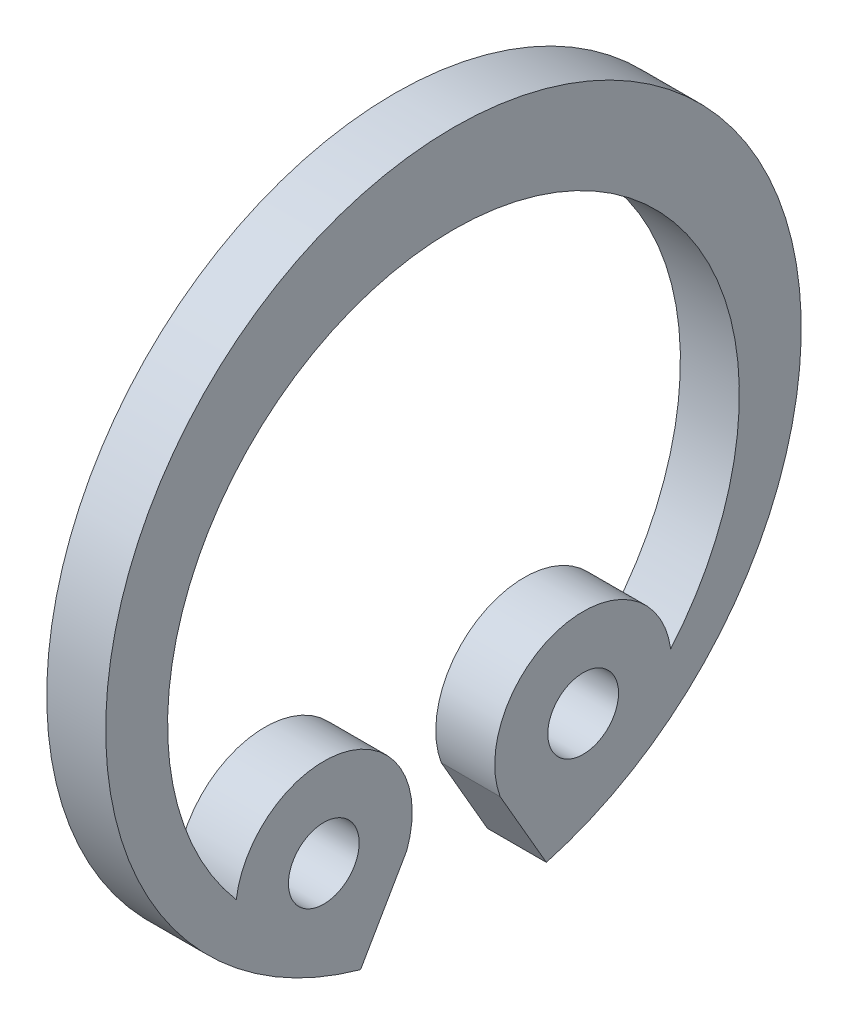
from build123d import *

# Parameters (mm, degrees)
BOSS_EXTRUDE1_DEPTH      = 0.5
BOSS_EXTRUDE1_DEPTH_BACK = 0.5
SKETCH1_R                = 0.6


with BuildPart() as part:
    # Sketch1 → Boss-Extrude1 (new, two sides: drawn at the far end of the back side and taken through both)
    with BuildSketch(Plane(origin=(0, 0, 0), x_dir=(0, 0, -1), z_dir=(1, 0, 0)).offset(-BOSS_EXTRUDE1_DEPTH_BACK)):
        with BuildLine():
            Line((-1.575903864, -5.685642181), (-0.792131706, -4.328108982))
            ThreePointArc((-0.792131706, -4.328108982), (-1.835210176, -2.355544978), (-3.685531471, -3.602674702))
            ThreePointArc((-3.685531471, -3.602674702), (0, 4.4), (3.685531471, -3.602674702))
            ThreePointArc((3.685531471, -3.602674702), (1.835210176, -2.355544978), (0.792131706, -4.328108982))
            Line((0.792131706, -4.328108982), (1.575903864, -5.685642181))
            ThreePointArc((1.575903864, -5.685642181), (0, 5.9), (-1.575903864, -5.685642181))
        make_face()
        with Locations((2.2, -3.810511777)):
            Circle(SKETCH1_R, mode=Mode.SUBTRACT)
        with Locations((-2.2, -3.810511777)):
            Circle(SKETCH1_R, mode=Mode.SUBTRACT)
    extrude(amount=BOSS_EXTRUDE1_DEPTH + BOSS_EXTRUDE1_DEPTH_BACK)


solid = part.part
